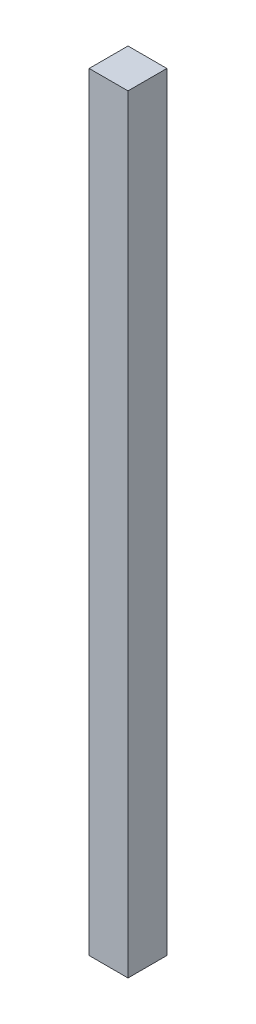
from build123d import *

# Parameters (mm, degrees)
ESQUISSE1_W        = 13
ESQUISSE1_H        = 257
BOSS_EXTRU_1_DEPTH = 13


with BuildPart() as part:
    # Esquisse1 → Boss.-Extru.1 (new body)
    with BuildSketch(Plane.XY):
        with Locations((-74.822185673, -50.861111111)):
            Rectangle(ESQUISSE1_W, ESQUISSE1_H)
    extrude(amount=BOSS_EXTRU_1_DEPTH)


solid = part.part
